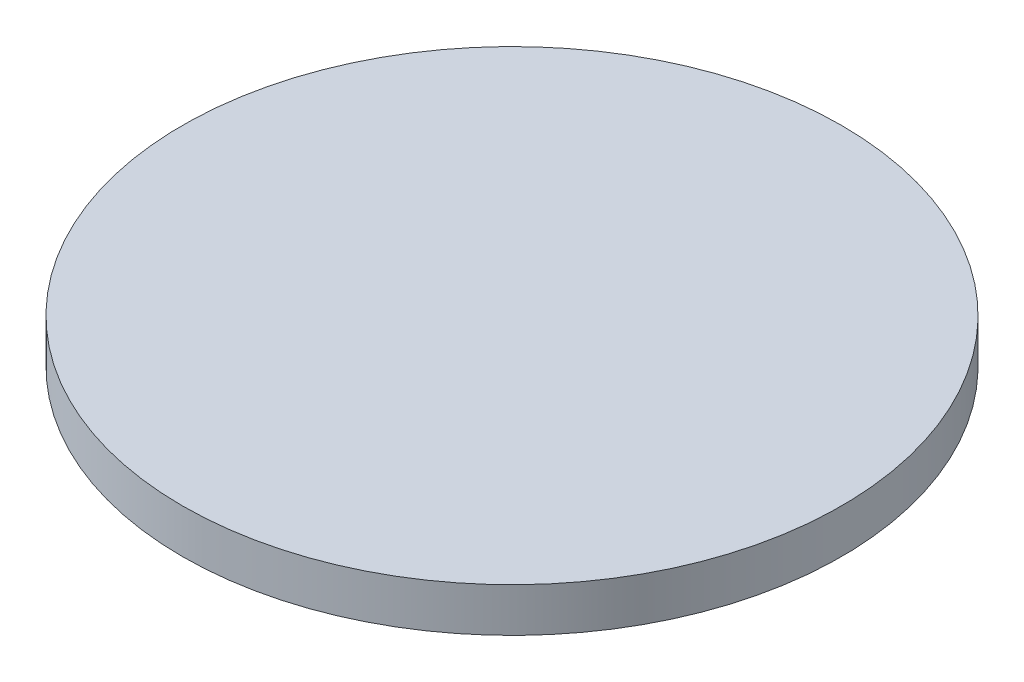
from build123d import *

# Parameters (mm, degrees)
SKETCH2_R          = 2.81
CUT_EXTRUDE1_DEPTH = 3.03


with BuildPart() as part:
    # Sketch1 → Revolve1 (revolve)
    with BuildSketch(Plane.XY):
        Polygon((0, 3.9), (-15, 3.9), (-15, 1.9), (-4.96, 1.9), (-4.96, 0), (0, 0), align=None)
    revolve(axis=Axis((0, 3.9, 0), (0, -1, 0)))

    # Sketch2 → Cut-Extrude1 (cut)
    with BuildSketch(Plane.XZ):
        Circle(SKETCH2_R)
    extrude(amount=-CUT_EXTRUDE1_DEPTH, mode=Mode.SUBTRACT)


solid = part.part
